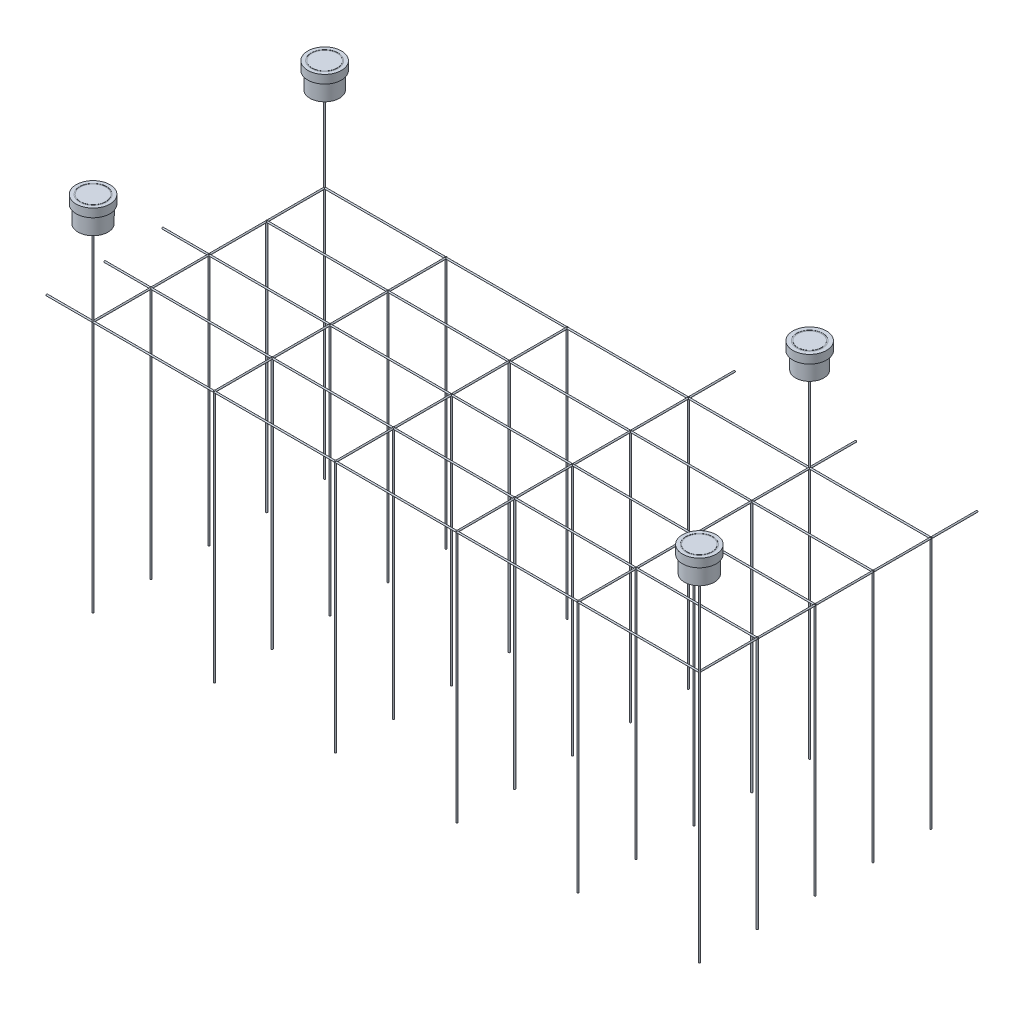
from build123d import *
from build123d.topology import SkipClean

# Parameters (mm, degrees)
CROQUIS1_R                   = 9
SALIENTE_EXTRUIR1_DEPTH      = 3000
SALIENTE_EXTRUIR1_2_DEPTH    = 3000
SALIENTE_EXTRUIR1_3_DEPTH    = 3000
SALIENTE_EXTRUIR1_4_DEPTH    = 3000
SALIENTE_EXTRUIR1_5_DEPTH    = 3000
SALIENTE_EXTRUIR1_6_DEPTH    = 3000
SALIENTE_EXTRUIR1_7_DEPTH    = 3000
SALIENTE_EXTRUIR1_8_DEPTH    = 3000
SALIENTE_EXTRUIR1_9_DEPTH    = 3000
SALIENTE_EXTRUIR1_10_DEPTH   = 3000
SALIENTE_EXTRUIR1_11_DEPTH   = 3000
SALIENTE_EXTRUIR1_12_DEPTH   = 3000
CROQUIS2_R                   = 9
SALIENTE_EXTRUIR2_DEPTH      = 3000
MATRIZL2_COUNT               = 4
MATRIZL2_PITCH               = 687.5
CROQUIS3_R                   = 9
SALIENTE_EXTRUIR3_DEPTH      = 3000
MATRIZL4_COUNT               = 6
MATRIZL4_PITCH               = 1440
SALIENTE_EXTRUIR4_DEPTH      = 3600
SALIENTE_EXTRUIR4_DEPTH_BACK = 3600
CROQUIS4_R                   = 9
SALIENTE_EXTRUIR5_DEPTH      = 3600
SALIENTE_EXTRUIR5_DEPTH_BACK = 3600
CROQUIS5_R                   = 9
SALIENTE_EXTRUIR6_DEPTH      = 1375
SALIENTE_EXTRUIR6_DEPTH_BACK = 1375
CROQUIS6_R                   = 9
SALIENTE_EXTRUIR7_START      = 1300
CROQUIS7_R                   = 9
SALIENTE_EXTRUIR7_DEPTH      = 1300
CROQUIS8_R                   = 200
SALIENTE_EXTRUIR8_DEPTH      = 100
CROQUIS9_R                   = 160
CROQUIS9_R_2                 = 150
CORTAR_EXTRUIR1_DEPTH        = 2
CROQUIS10_R                  = 178.03925502
SALIENTE_EXTRUIR9_DEPTH      = 200
MATRIZL6_COUNT               = 2
MATRIZL6_PITCH               = 7200
SALIENTE_EXTRUIR11_START     = 1300
CROQUIS12_R                  = 9
SALIENTE_EXTRUIR11_DEPTH     = 1300
CROQUIS13_R                  = 200
SALIENTE_EXTRUIR12_DEPTH     = 100
CROQUIS14_R                  = 175
SALIENTE_EXTRUIR13_DEPTH     = 200
CROQUIS15_R                  = 160
CROQUIS15_R_2                = 150
CORTAR_EXTRUIR2_DEPTH        = 2
CROQUIS26_R                  = 9
SALIENTE_EXTRUIR18_DEPTH     = 550
CROQUIS28_R                  = 9
SALIENTE_EXTRUIR19_DEPTH     = 550
MATRIZL7_COUNT               = 3
MATRIZL7_PITCH               = 687.5
MATRIZL8_COUNT               = 3
MATRIZL8_PITCH               = 1440
SALIENTE_EXTRUIR20_START     = 1300
CROQUIS29_R                  = 9
SALIENTE_EXTRUIR20_DEPTH     = 1300
CROQUIS30_R                  = 200
SALIENTE_EXTRUIR21_DEPTH     = 100
CROQUIS31_R                  = 167.911885626
SALIENTE_EXTRUIR22_DEPTH     = 200
CROQUIS32_R                  = 154.142526526
CROQUIS32_R_2                = 141.003953945
CORTAR_EXTRUIR4_DEPTH        = 2


with BuildPart() as part:
    # Croquis1 → Saliente-Extruir1 (new body)
    with BuildSketch(Plane(origin=(0, 0, 0), x_dir=(1, 0, 0), z_dir=(0, 1, 0))):
        with Locations((-3600, 1375)):
            Circle(CROQUIS1_R)
    extrude(amount=-SALIENTE_EXTRUIR1_DEPTH)

    # Croquis2 → Saliente-Extruir2 (add)
    with BuildSketch(Plane(origin=(0, 0, 0), x_dir=(1, 0, 0), z_dir=(0, 1, 0))):
        with Locations((-3600, 1375)):
            Circle(CROQUIS2_R)
    saliente_extruir2 = extrude(amount=-SALIENTE_EXTRUIR2_DEPTH)



with BuildPart() as body_2:
    # Croquis1 → Saliente-Extruir1 2 (new body)
    with BuildSketch(Plane(origin=(0, 0, 0), x_dir=(1, 0, 0), z_dir=(0, 1, 0))):
        with Locations((-2160, 1375)):
            Circle(CROQUIS1_R)
    extrude(amount=-SALIENTE_EXTRUIR1_2_DEPTH)


with BuildPart() as body_3:
    # Croquis1 → Saliente-Extruir1 3 (new body)
    with BuildSketch(Plane(origin=(0, 0, 0), x_dir=(1, 0, 0), z_dir=(0, 1, 0))):
        with Locations((-720, 1375)):
            Circle(CROQUIS1_R)
    extrude(amount=-SALIENTE_EXTRUIR1_3_DEPTH)


with BuildPart() as body_4:
    # Croquis1 → Saliente-Extruir1 4 (new body)
    with BuildSketch(Plane(origin=(0, 0, 0), x_dir=(1, 0, 0), z_dir=(0, 1, 0))):
        with Locations((720, 1375)):
            Circle(CROQUIS1_R)
    extrude(amount=-SALIENTE_EXTRUIR1_4_DEPTH)


with BuildPart() as body_5:
    # Croquis1 → Saliente-Extruir1 5 (new body)
    with BuildSketch(Plane(origin=(0, 0, 0), x_dir=(1, 0, 0), z_dir=(0, 1, 0))):
        with Locations((2160, 1375)):
            Circle(CROQUIS1_R)
    extrude(amount=-SALIENTE_EXTRUIR1_5_DEPTH)


with BuildPart() as body_6:
    # Croquis1 → Saliente-Extruir1 6 (new body)
    with BuildSketch(Plane(origin=(0, 0, 0), x_dir=(1, 0, 0), z_dir=(0, 1, 0))):
        with Locations((3600, 1375)):
            Circle(CROQUIS1_R)
    extrude(amount=-SALIENTE_EXTRUIR1_6_DEPTH)


with BuildPart() as body_7:
    # Croquis1 → Saliente-Extruir1 7 (new body)
    with BuildSketch(Plane(origin=(0, 0, 0), x_dir=(1, 0, 0), z_dir=(0, 1, 0))):
        with Locations((-3600, -1375)):
            Circle(CROQUIS1_R)
    extrude(amount=-SALIENTE_EXTRUIR1_7_DEPTH)



with BuildPart() as body_8:
    # Croquis1 → Saliente-Extruir1 8 (new body)
    with BuildSketch(Plane(origin=(0, 0, 0), x_dir=(1, 0, 0), z_dir=(0, 1, 0))):
        with Locations((-2160, -1375)):
            Circle(CROQUIS1_R)
    extrude(amount=-SALIENTE_EXTRUIR1_8_DEPTH)


with BuildPart() as body_9:
    # Croquis1 → Saliente-Extruir1 9 (new body)
    with BuildSketch(Plane(origin=(0, 0, 0), x_dir=(1, 0, 0), z_dir=(0, 1, 0))):
        with Locations((-720, -1375)):
            Circle(CROQUIS1_R)
    extrude(amount=-SALIENTE_EXTRUIR1_9_DEPTH)


with BuildPart() as body_10:
    # Croquis1 → Saliente-Extruir1 10 (new body)
    with BuildSketch(Plane(origin=(0, 0, 0), x_dir=(1, 0, 0), z_dir=(0, 1, 0))):
        with Locations((720, -1375)):
            Circle(CROQUIS1_R)
    extrude(amount=-SALIENTE_EXTRUIR1_10_DEPTH)


with BuildPart() as body_11:
    # Croquis1 → Saliente-Extruir1 11 (new body)
    with BuildSketch(Plane(origin=(0, 0, 0), x_dir=(1, 0, 0), z_dir=(0, 1, 0))):
        with Locations((2160, -1375)):
            Circle(CROQUIS1_R)
    extrude(amount=-SALIENTE_EXTRUIR1_11_DEPTH)


with BuildPart() as body_12:
    # Croquis1 → Saliente-Extruir1 12 (new body)
    with BuildSketch(Plane(origin=(0, 0, 0), x_dir=(1, 0, 0), z_dir=(0, 1, 0))):
        with Locations((3600, -1375)):
            Circle(CROQUIS1_R)
    extrude(amount=-SALIENTE_EXTRUIR1_12_DEPTH)


with BuildPart() as matrizl2_1:
    # MatrizL2: Saliente-Extruir2 ×4
    with Locations(*[(0, 0, i * MATRIZL2_PITCH) for i in range(1, MATRIZL2_COUNT)]):
        add(saliente_extruir2)

    # Croquis3 → Saliente-Extruir3 (add)
    with BuildSketch(Plane(origin=(0, 0, 0), x_dir=(1, 0, 0), z_dir=(0, 1, 0))):
        with Locations((-3600, -687.5)):
            Circle(CROQUIS3_R)
        with Locations((-3600, 0)):
            Circle(CROQUIS3_R)
        with Locations((-3600, 687.5)):
            Circle(CROQUIS3_R)
    saliente_extruir3 = extrude(amount=-SALIENTE_EXTRUIR3_DEPTH)


with BuildPart() as matrizl4_1:
    # MatrizL4: Saliente-Extruir3 ×6
    with Locations(*[(i * MATRIZL4_PITCH, 0, 0) for i in range(1, MATRIZL4_COUNT)]):
        add(saliente_extruir3)


with BuildPart() as part_1:
    add(part.part)

    add(body_2.part)  # Saliente-Extruir4 merges body 2

    add(body_3.part)  # Saliente-Extruir4 merges body 3

    add(body_4.part)  # Saliente-Extruir4 merges body 4

    add(body_5.part)  # Saliente-Extruir4 merges body 5

    add(body_6.part)  # Saliente-Extruir4 merges body 6
    # Croquis4 → Saliente-Extruir4 (add, two sides: drawn at the far end of the back side and taken through both)
    with BuildSketch(Plane(origin=(0, 0, 0), x_dir=(0, 0, -1), z_dir=(1, 0, 0)).offset(-SALIENTE_EXTRUIR4_DEPTH_BACK)):
        with Locations((1375, -9)):
            Circle(CROQUIS4_R)
    extrude(amount=SALIENTE_EXTRUIR4_DEPTH + SALIENTE_EXTRUIR4_DEPTH_BACK)



with BuildPart() as body_7_1:
    add(body_7.part)

    add(body_8.part)  # Saliente-Extruir5 merges body 8

    add(body_9.part)  # Saliente-Extruir5 merges body 9

    add(body_10.part)  # Saliente-Extruir5 merges body 10

    add(body_11.part)  # Saliente-Extruir5 merges body 11

    add(body_12.part)  # Saliente-Extruir5 merges body 12

    add(matrizl2_1.part)  # Saliente-Extruir5 merges MatrizL2_1

    add(matrizl4_1.part)  # Saliente-Extruir5 merges MatrizL4_1
    # Croquis5 → Saliente-Extruir5 (add, two sides: drawn at the far end of the back side and taken through both)
    with BuildSketch(Plane(origin=(0, 0, 0), x_dir=(0, 0, -1), z_dir=(1, 0, 0)).offset(-SALIENTE_EXTRUIR5_DEPTH_BACK)):
        with Locations((687.5, -9)):
            Circle(CROQUIS5_R)
        with Locations((0, -9)):
            Circle(CROQUIS5_R)
        with Locations((-687.5, -9)):
            Circle(CROQUIS5_R)
        with Locations((-1375, -9)):
            Circle(CROQUIS5_R)
    extrude(amount=SALIENTE_EXTRUIR5_DEPTH + SALIENTE_EXTRUIR5_DEPTH_BACK)


with BuildPart() as part_2:
    with SkipClean():  # the faces are left unmerged after this step: merging them gives an invalid solid
        add(part_1.part)

        add(body_7_1.part)  # Saliente-Extruir6 merges body 7
        # Croquis6 → Saliente-Extruir6 (add, two sides: drawn at the far end of the back side and taken through both)
        with BuildSketch(Plane.XY.offset(-SALIENTE_EXTRUIR6_DEPTH_BACK)):
            with Locations((-3600, -9)):
                Circle(CROQUIS6_R)
            with Locations((-2160, -9)):
                Circle(CROQUIS6_R)
            with Locations((-720, -9)):
                Circle(CROQUIS6_R)
            with Locations((720, -9)):
                Circle(CROQUIS6_R)
            with Locations((2160, -9)):
                Circle(CROQUIS6_R)
            with Locations((3600, -9)):
                Circle(CROQUIS6_R)
        extrude(amount=SALIENTE_EXTRUIR6_DEPTH + SALIENTE_EXTRUIR6_DEPTH_BACK)

    # Croquis7 → Saliente-Extruir7 (add)
    with SkipClean():  # the faces are left unmerged after this step: merging them gives an invalid solid
        with BuildSketch(Plane(origin=(0, 0, 0), x_dir=(1, 0, 0), z_dir=(0, 1, 0)).offset(SALIENTE_EXTRUIR7_START)):
            with Locations((3600, -1375)):
                Circle(CROQUIS7_R)
        saliente_extruir7 = extrude(amount=-SALIENTE_EXTRUIR7_DEPTH)

    # Croquis8 → Saliente-Extruir8 (add)
    with SkipClean():  # the faces are left unmerged after this step: merging them gives an invalid solid
        with BuildSketch(Plane(origin=(0, 1300, 0), x_dir=(1, 0, 0), z_dir=(0, 1, 0))):
            with Locations((3600, -1375)):
                Circle(CROQUIS8_R)
        saliente_extruir8 = extrude(amount=-SALIENTE_EXTRUIR8_DEPTH)

    # Croquis9 → Cortar-Extruir1 (cut)
    with SkipClean():  # the faces are left unmerged after this step: merging them gives an invalid solid
        with BuildSketch(Plane(origin=(0, 1300, 0), x_dir=(1, 0, 0), z_dir=(0, 1, 0))):
            with Locations((3600, -1375)):
                Circle(CROQUIS9_R)
            with Locations((3600, -1375)):
                Circle(CROQUIS9_R_2, mode=Mode.SUBTRACT)
        cortar_extruir1 = extrude(amount=-CORTAR_EXTRUIR1_DEPTH, mode=Mode.SUBTRACT)

    # Croquis10 → Saliente-Extruir9 (add)
    with SkipClean():  # the faces are left unmerged after this step: merging them gives an invalid solid
        with BuildSketch(Plane.XZ.offset(-1200)):
            with Locations((3600, 1375)):
                Circle(CROQUIS10_R)
        saliente_extruir9 = extrude(amount=SALIENTE_EXTRUIR9_DEPTH)

    # MatrizL6: Saliente-Extruir7, Saliente-Extruir8, Cortar-Extruir1, Saliente-Extruir9 ×2
    with SkipClean():  # the faces are left unmerged after this step: merging them gives an invalid solid
        with Locations(*[(-i * MATRIZL6_PITCH, 0, 0) for i in range(1, MATRIZL6_COUNT)]):
            add(saliente_extruir7)
            add(saliente_extruir8)
            add(cortar_extruir1, mode=Mode.SUBTRACT)
            add(saliente_extruir9)

    # Croquis12 → Saliente-Extruir11 (add)
    with SkipClean():  # the faces are left unmerged after this step: merging them gives an invalid solid
        with BuildSketch(Plane(origin=(0, 0, 0), x_dir=(1, 0, 0), z_dir=(0, 1, 0)).offset(SALIENTE_EXTRUIR11_START)):
            with Locations((-3600, 1375)):
                Circle(CROQUIS12_R)
        extrude(amount=-SALIENTE_EXTRUIR11_DEPTH)

    # Croquis13 → Saliente-Extruir12 (add)
    with SkipClean():  # the faces are left unmerged after this step: merging them gives an invalid solid
        with BuildSketch(Plane(origin=(0, 1300, 0), x_dir=(1, 0, 0), z_dir=(0, 1, 0))):
            with Locations((-3600, 1375)):
                Circle(CROQUIS13_R)
        extrude(amount=-SALIENTE_EXTRUIR12_DEPTH)

    # Croquis14 → Saliente-Extruir13 (add)
    with SkipClean():  # the faces are left unmerged after this step: merging them gives an invalid solid
        with BuildSketch(Plane.XZ.offset(-1200)):
            with Locations((-3600, -1375)):
                Circle(CROQUIS14_R)
        extrude(amount=SALIENTE_EXTRUIR13_DEPTH)

    # Croquis15 → Cortar-Extruir2 (cut)
    with SkipClean():  # the faces are left unmerged after this step: merging them gives an invalid solid
        with BuildSketch(Plane(origin=(0, 1300, 0), x_dir=(1, 0, 0), z_dir=(0, 1, 0))):
            with Locations((-3600, 1375)):
                Circle(CROQUIS15_R)
            with Locations((-3600, 1375)):
                Circle(CROQUIS15_R_2, mode=Mode.SUBTRACT)
        extrude(amount=-CORTAR_EXTRUIR2_DEPTH, mode=Mode.SUBTRACT)

    # Croquis26 → Saliente-Extruir18 (add)
    with BuildSketch(Plane(origin=(0, 0, -1375), x_dir=(-1, 0, 0), z_dir=(0, 0, -1))):
        with Locations((-3600, -9)):
            Circle(CROQUIS26_R)
    saliente_extruir18 = extrude(amount=SALIENTE_EXTRUIR18_DEPTH)

    # Croquis28 → Saliente-Extruir19 (add)
    with BuildSketch(Plane.ZY.offset(3600)):
        with Locations((1375, -9)):
            Circle(CROQUIS28_R)
    saliente_extruir19 = extrude(amount=SALIENTE_EXTRUIR19_DEPTH)

    # MatrizL7: Saliente-Extruir19 ×3
    with Locations(*[(0, 0, -i * MATRIZL7_PITCH) for i in range(1, MATRIZL7_COUNT)]):
        add(saliente_extruir19)

    # MatrizL8: Saliente-Extruir18 ×3
    with Locations(*[(-i * MATRIZL8_PITCH, 0, 0) for i in range(1, MATRIZL8_COUNT)]):
        add(saliente_extruir18)

    # Croquis29 → Saliente-Extruir20 (add)
    with BuildSketch(Plane(origin=(0, 0, 0), x_dir=(1, 0, 0), z_dir=(0, 1, 0)).offset(SALIENTE_EXTRUIR20_START)):
        with Locations((2160, 1375)):
            Circle(CROQUIS29_R)
    extrude(amount=-SALIENTE_EXTRUIR20_DEPTH)

    # Croquis30 → Saliente-Extruir21 (add)
    with BuildSketch(Plane(origin=(0, 1300, 0), x_dir=(1, 0, 0), z_dir=(0, 1, 0))):
        with Locations((2160, 1375)):
            Circle(CROQUIS30_R)
    extrude(amount=-SALIENTE_EXTRUIR21_DEPTH)

    # Croquis31 → Saliente-Extruir22 (add)
    with BuildSketch(Plane.XZ.offset(-1200)):
        with Locations((2160, -1375)):
            Circle(CROQUIS31_R)
    extrude(amount=SALIENTE_EXTRUIR22_DEPTH)

    # Croquis32 → Cortar-Extruir4 (cut)
    with BuildSketch(Plane(origin=(0, 1300, 0), x_dir=(1, 0, 0), z_dir=(0, 1, 0))):
        with Locations((2160, 1375)):
            Circle(CROQUIS32_R)
        with Locations((2160, 1375)):
            Circle(CROQUIS32_R_2, mode=Mode.SUBTRACT)
    extrude(amount=-CORTAR_EXTRUIR4_DEPTH, mode=Mode.SUBTRACT)


solid = part_2.part
